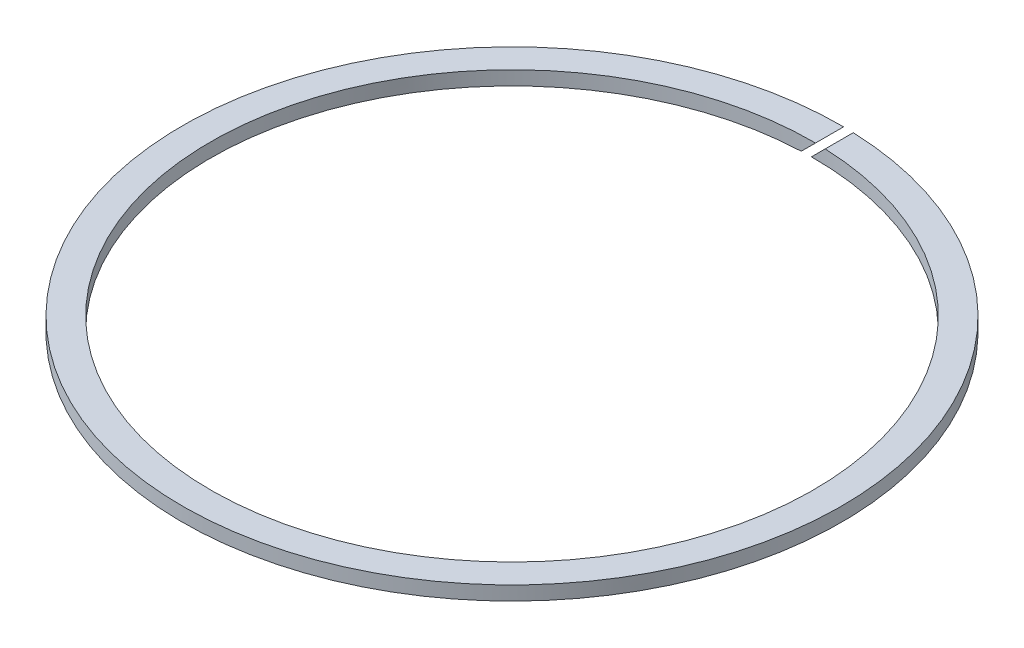
from build123d import *

# Parameters (mm, degrees)
SKETCH1_R           = 47
SKETCH1_R_2         = 43
BOSS_EXTRUDE1_DEPTH = 1
CUT_EXTRUDE1_DEPTH  = 48


with BuildPart() as part:
    # Sketch1 → Boss-Extrude1 (new body, symmetric)
    with BuildSketch(Plane(origin=(0, 0, 0), x_dir=(1, 0, 0), z_dir=(0, 1, 0))):
        Circle(SKETCH1_R)
        Circle(SKETCH1_R_2, mode=Mode.SUBTRACT)
    extrude(amount=BOSS_EXTRUDE1_DEPTH, both=True)

    # Sketch2 → Cut-Extrude1 (cut, through all)
    with BuildSketch(Plane.XY):
        Polygon((-7.424621202, -6.717514421), (6.717514421, 7.424621202), (7.424621202, 6.717514421), (-6.717514421, -7.424621202), align=None)
    extrude(amount=-CUT_EXTRUDE1_DEPTH, mode=Mode.SUBTRACT)


solid = part.part
